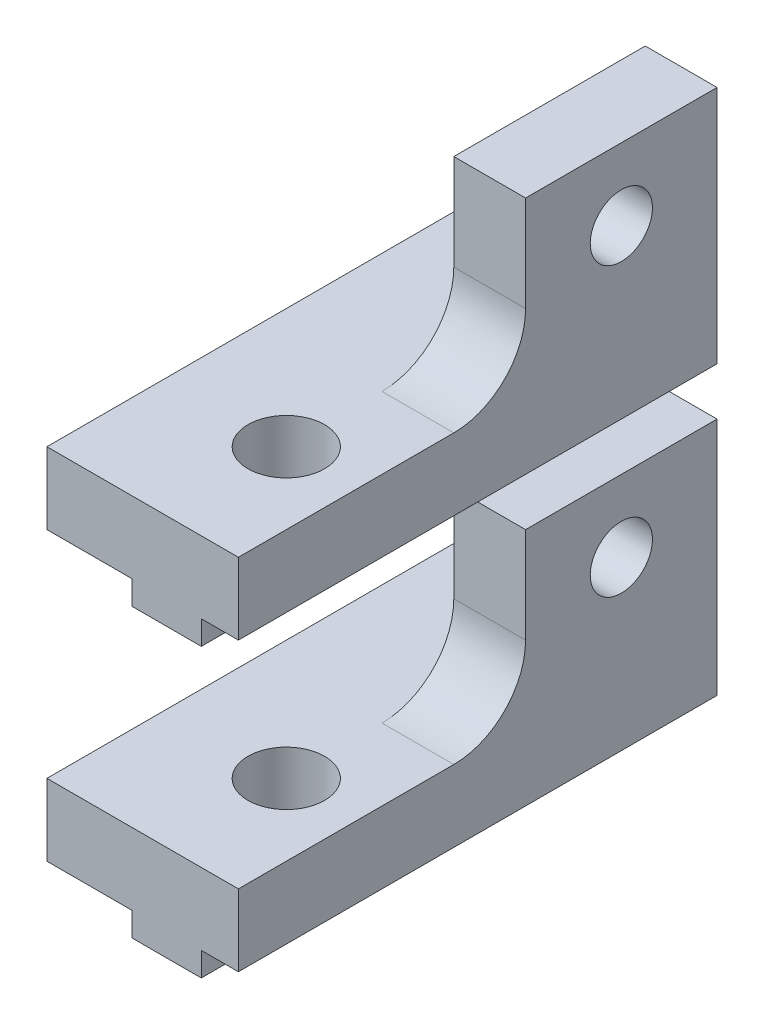
from build123d import *

# Parameters (mm, degrees)
MAIN_DEPTH                 = 20
ESQUISSE2_R                = 1.3
VERTICAL_HOLE_DEPTH        = 1
VERTICAL_HOLE_DEPTH_BACK   = 9
ESQUISSE6_W                = 12
ESQUISSE6_H                = 7
CUT_BORDERS_DEPTH          = 4
ESQUISSE7_W                = 2.9
ESQUISSE7_H                = 1
MAKERBEAMSUPPORT_DEPTH     = 20
ESQUISSE3_R                = 1.6
HORIZONTAL_HOLE_DEPTH      = 10
HORIZONTAL_HOLE_DEPTH_BACK = 8
CONG_1_R                   = 3
LPATTERN1_COUNT            = 2
LPATTERN1_PITCH            = 12


with BuildPart() as part:
    # Esquisse1 → Main (new body)
    with BuildSketch(Plane.XY):
        Polygon((0, 0), (8, 0), (8, 10), (5, 10), (5, 3), (0, 3), align=None)
    extrude(amount=MAIN_DEPTH)

    # Esquisse2 → Vertical Hole (cut, two sides)
    with BuildSketch(Plane.ZY) as vertical_hole_sk:
        with Locations((4, 7)):
            Circle(ESQUISSE2_R)
    extrude(amount=VERTICAL_HOLE_DEPTH, mode=Mode.SUBTRACT)
    extrude(vertical_hole_sk.sketch, amount=-VERTICAL_HOLE_DEPTH_BACK, mode=Mode.SUBTRACT)

    # Esquisse6 → Cut Borders (cut, through all)
    with BuildSketch(Plane(origin=(5, 0, 0), x_dir=(0, 0, -1), z_dir=(1, 0, 0))):
        with Locations((-14, 6.5)):
            Rectangle(ESQUISSE6_W, ESQUISSE6_H)
    extrude(amount=CUT_BORDERS_DEPTH, mode=Mode.SUBTRACT)

    # Esquisse7 → MakerBeamSupport (add)
    with BuildSketch(Plane.XY.offset(20)):
        with Locations((5, -0.5)):
            Rectangle(ESQUISSE7_W, ESQUISSE7_H)
    extrude(amount=-MAKERBEAMSUPPORT_DEPTH)

    # Esquisse3 → Horizontal Hole (cut, two sides)
    with BuildSketch(Plane.XZ.offset(-3)) as horizontal_hole_sk:
        with Locations((5, 15)):
            Circle(ESQUISSE3_R)
    extrude(amount=HORIZONTAL_HOLE_DEPTH, mode=Mode.SUBTRACT)
    extrude(horizontal_hole_sk.sketch, amount=-HORIZONTAL_HOLE_DEPTH_BACK, mode=Mode.SUBTRACT)

    # Congé1
    cong_1_edges = [part.edges().sort_by_distance(p)[0] for p in [
        (6.5, 3, 8),
    ]]
    fillet(cong_1_edges, radius=CONG_1_R)


with BuildPart() as lpattern1_1:
    # LPattern1: pattern copy
    add(part.part.moved(Location(Vector(0, 1, 0) * (1 * LPATTERN1_PITCH))))


solid = Compound([part.part, lpattern1_1.part])
